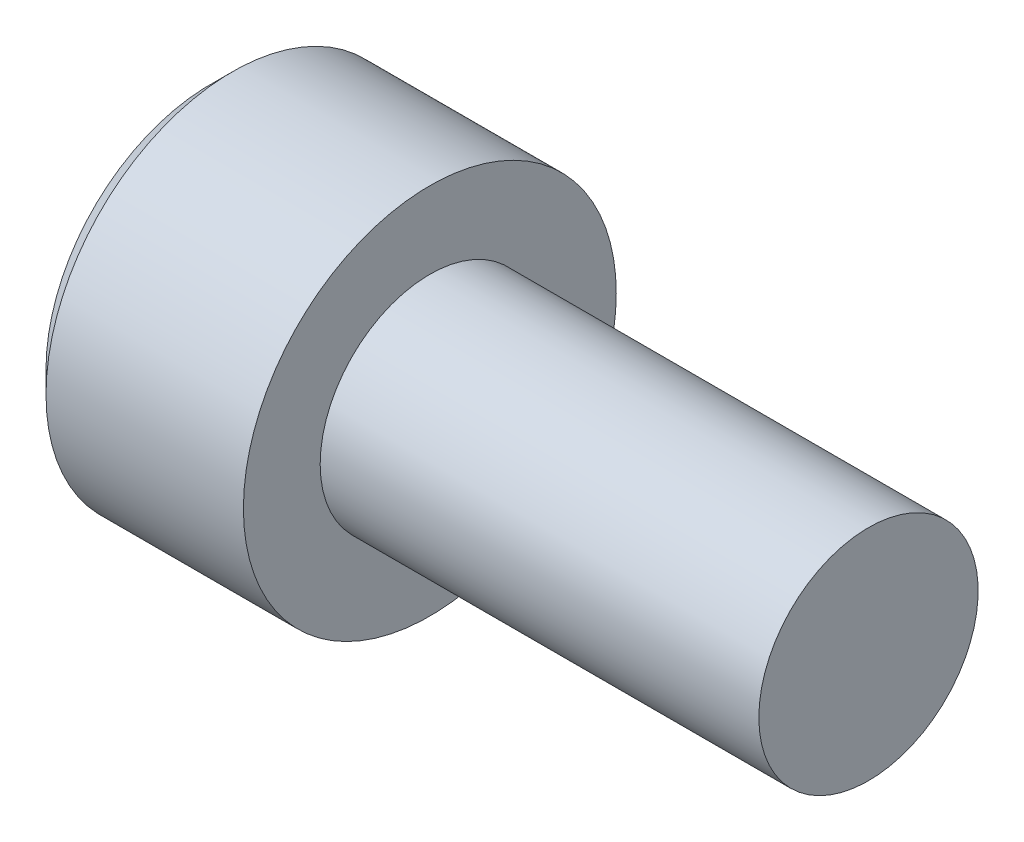
from build123d import *

# Parameters (mm, degrees)
CHAMFER1_SIZE      = 0.5
CUT_EXTRUDE1_DEPTH = 2.5


with BuildPart() as part:
    # Sketch1 → Revolve1 (revolve)
    with BuildSketch(Plane.XY):
        Polygon((-5, 0), (10, 0), (10, 2.5), (0, 2.5), (0, 4.25), (-5, 4.25), align=None)
    revolve(axis=Axis((-5, 0, 0), (1, 0, 0)))

    # Chamfer1
    chamfer1_edges = [part.edges().sort_by_distance(p)[0] for p in [
        (-5, -4.25, 0),
    ]]
    chamfer(chamfer1_edges, length=CHAMFER1_SIZE)

    # Sketch2 → Cut-Revolve1 (revolve, cut)
    with BuildSketch(Plane.XY):
        Polygon((-1.298278762, 0), (-2.5, 2), (-5, 2), (-5, 0), align=None)
    revolve(axis=Axis((-5, 0, 0), (1, 0, 0)), mode=Mode.SUBTRACT)

    # Sketch3 → Cut-Extrude1 (cut)
    with BuildSketch(Plane.ZY.offset(5)):
        Polygon((0, -2.309401077), (2, -1.154700538), (2, 1.154700538), (0, 2.309401077), (-2, 1.154700538), (-2, -1.154700538), align=None)
    extrude(amount=-CUT_EXTRUDE1_DEPTH, mode=Mode.SUBTRACT)


solid = part.part
